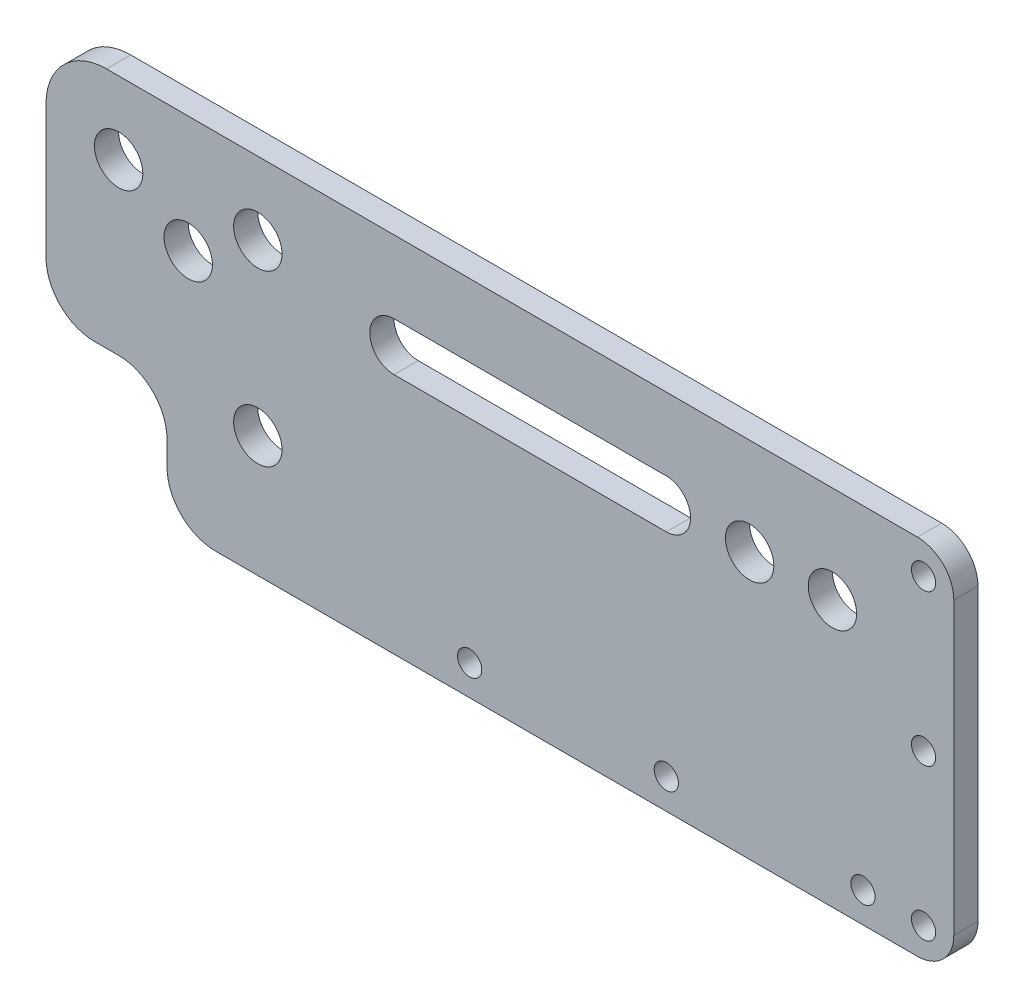
from build123d import *

# Parameters (mm, degrees)
SKETCH1_R           = 4
SKETCH1_R_2         = 2
BOSS_EXTRUDE1_DEPTH = 4


with BuildPart() as part:
    # Sketch1 → Boss-Extrude1 (new body)
    with BuildSketch(Plane.XY):
        with BuildLine():
            Line((28, 0), (140, 0))
            Line((140, 0), (144, 0))
            ThreePointArc((144, 0), (148.242640687, 1.757359313), (150, 6))
            Line((150, 6), (150, 54))
            ThreePointArc((150, 54), (148.242640687, 58.242640687), (144, 60))
            Line((144, 60), (140, 60))
            Line((140, 60), (10, 60))
            ThreePointArc((10, 60), (2.928932188, 57.071067812), (0, 50))
            Line((0, 50), (0, 28))
            ThreePointArc((0, 28), (2.343145751, 22.343145751), (8, 20))
            Line((8, 20), (12, 20))
            ThreePointArc((12, 20), (17.656854249, 17.656854249), (20, 12))
            Line((20, 12), (20, 8))
            ThreePointArc((20, 8), (22.343145751, 2.343145751), (28, 0))
        make_face()
        with Locations((35, 20)):
            Circle(SKETCH1_R, mode=Mode.SUBTRACT)
        with Locations((116.264838239, 44)):
            Circle(SKETCH1_R, mode=Mode.SUBTRACT)
        with Locations((129.947688147, 44)):
            Circle(SKETCH1_R, mode=Mode.SUBTRACT)
        with Locations((12, 48)):
            Circle(SKETCH1_R, mode=Mode.SUBTRACT)
        with Locations((23.5, 40.719874776)):
            Circle(SKETCH1_R, mode=Mode.SUBTRACT)
        with Locations((35, 48)):
            Circle(SKETCH1_R, mode=Mode.SUBTRACT)
        with Locations((135, 5)):
            Circle(SKETCH1_R_2, mode=Mode.SUBTRACT)
        with Locations((102.5, 5)):
            Circle(SKETCH1_R_2, mode=Mode.SUBTRACT)
        with Locations((70, 5)):
            Circle(SKETCH1_R_2, mode=Mode.SUBTRACT)
        with Locations((145, 54.898560305)):
            Circle(SKETCH1_R_2, mode=Mode.SUBTRACT)
        with Locations((145, 29.898560305)):
            Circle(SKETCH1_R_2, mode=Mode.SUBTRACT)
        with Locations((145, 4.898560305)):
            Circle(SKETCH1_R_2, mode=Mode.SUBTRACT)
        with BuildLine():
            Line((57.5, 48), (102.5, 48))
            ThreePointArc((102.5, 48), (106.5, 44), (102.5, 40))
            Line((102.5, 40), (57.5, 40))
            ThreePointArc((57.5, 40), (53.5, 44), (57.5, 48))
        make_face(mode=Mode.SUBTRACT)
    extrude(amount=BOSS_EXTRUDE1_DEPTH)


solid = part.part
